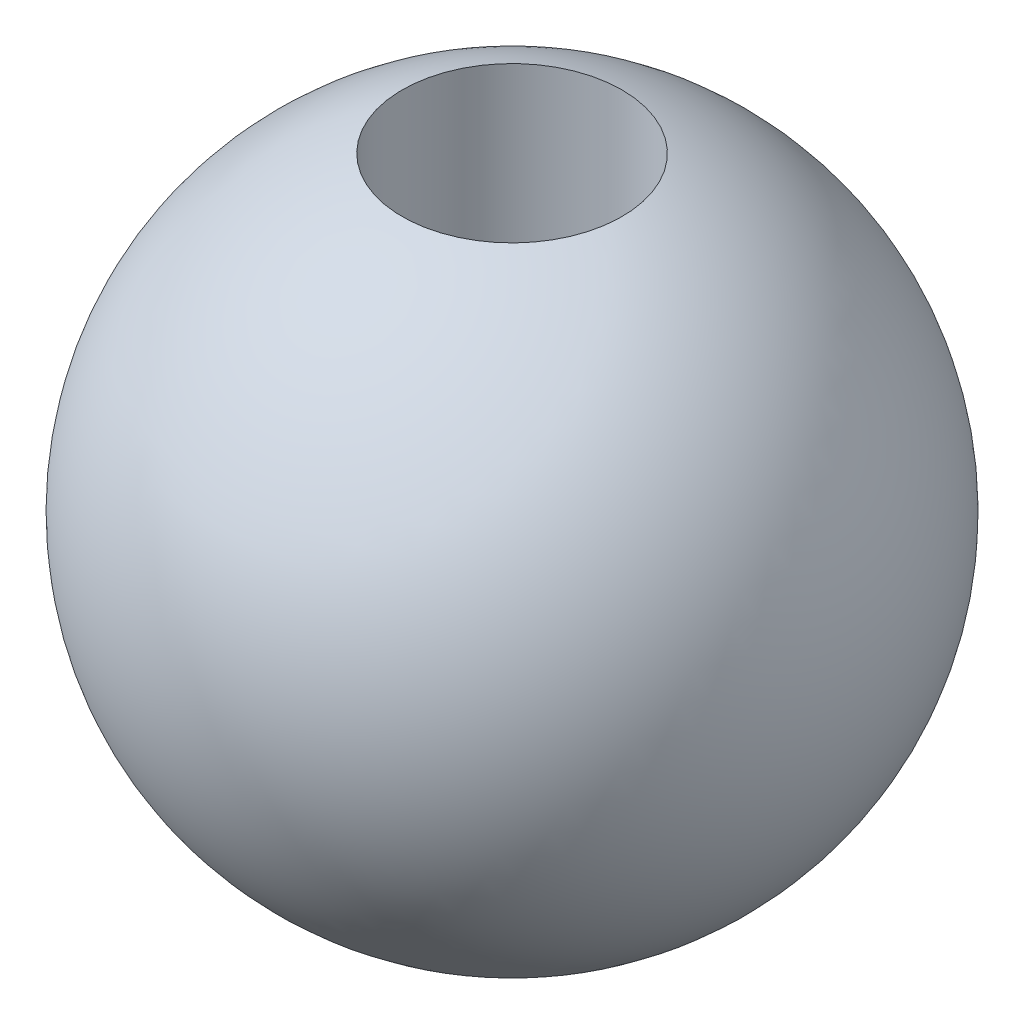
from build123d import *


with BuildPart() as part:
    # Sketch1 → Revolve1 (revolve)
    with BuildSketch(Plane.XY):
        with BuildLine():
            Line((0.5, 1.414213562), (0.5, -1.414213562))
            ThreePointArc((0.5, -1.414213562), (1.5, 0), (0.5, 1.414213562))
        make_face()
    revolve(axis=Axis((0, -1.5, 0), (0, 1, 0)))


solid = part.part
